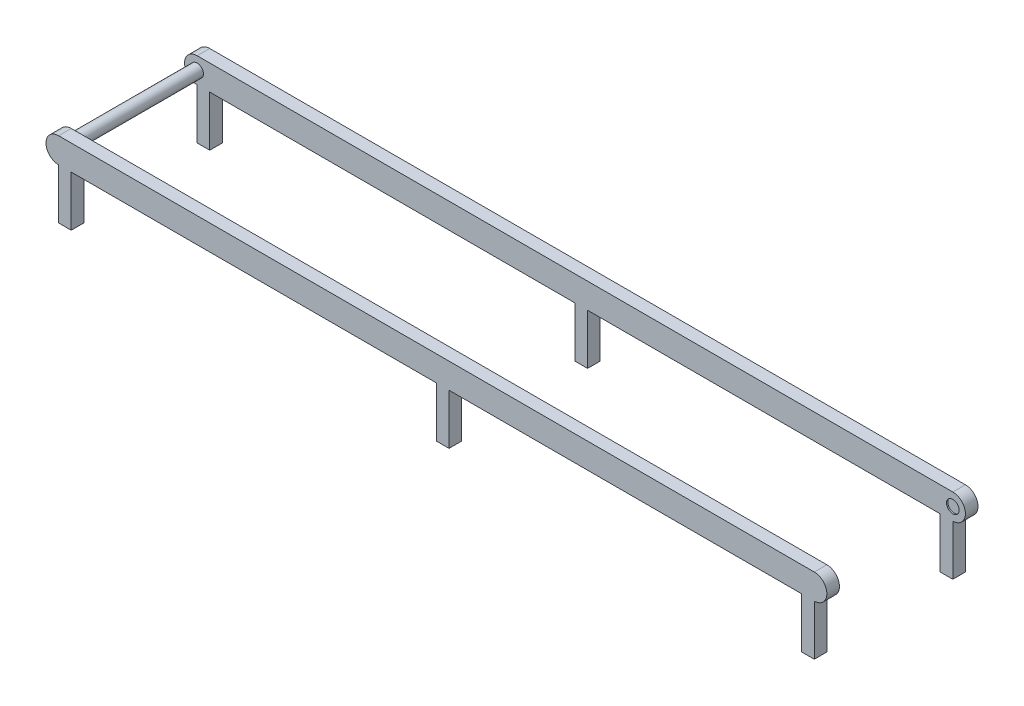
from build123d import *

# Parameters (mm, degrees)
SALIENTE_EXTRUIR1_DEPTH = 10
CROQUIS2_R              = 5
SALIENTE_EXTRUIR2_DEPTH = 100
CROQUIS5_R              = 5
CORTAR_EXTRUIR1_DEPTH   = 1
SALIENTE_EXTRUIR5_DEPTH = 10
CROQUIS7_W              = 10
CROQUIS7_H              = 10
SALIENTE_EXTRUIR6_DEPTH = 40


with BuildPart() as part:
    # Croquis1 → Saliente-Extruir1 (new body)
    with BuildSketch(Plane.XY):
        with BuildLine():
            Line((-300, 10), (300, 10))
            ThreePointArc((300, 10), (310, 0), (300, -10))
            Line((300, -10), (-300, -10))
            ThreePointArc((-300, -10), (-310, 0), (-300, 10))
        make_face()
    extrude(amount=SALIENTE_EXTRUIR1_DEPTH)

    # Croquis2 → Saliente-Extruir2 (add)
    with BuildSketch(Plane.XY.offset(10)):
        with Locations((-300, 0)):
            Circle(CROQUIS2_R)
    extrude(amount=SALIENTE_EXTRUIR2_DEPTH)

    # Croquis5 → Cortar-Extruir1 (cut)
    with BuildSketch(Plane.XY.offset(10)):
        with Locations((300, 0)):
            Circle(CROQUIS5_R)
    extrude(amount=-CORTAR_EXTRUIR1_DEPTH, mode=Mode.SUBTRACT)

    # Croquis6 → Saliente-Extruir5 (add)
    with BuildSketch(Plane.XY.offset(110)):
        with BuildLine():
            Line((-300, -10), (300, -10))
            ThreePointArc((300, -10), (310, 0), (300, 10))
            Line((300, 10), (-300, 10))
            ThreePointArc((-300, 10), (-310, 0), (-300, -10))
        make_face()
    extrude(amount=SALIENTE_EXTRUIR5_DEPTH)

    # Croquis7 → Saliente-Extruir6 (add)
    with BuildSketch(Plane.XZ.offset(10)):
        with Locations((-295, 5)):
            Rectangle(CROQUIS7_W, CROQUIS7_H)
        with Locations((295, 5)):
            Rectangle(CROQUIS7_W, CROQUIS7_H)
        with Locations((295, 115)):
            Rectangle(CROQUIS7_W, CROQUIS7_H)
        with Locations((-295, 115)):
            Rectangle(CROQUIS7_W, CROQUIS7_H)
        with Locations((5, 5)):
            Rectangle(CROQUIS7_W, CROQUIS7_H)
        with Locations((5, 115)):
            Rectangle(CROQUIS7_W, CROQUIS7_H)
    extrude(amount=SALIENTE_EXTRUIR6_DEPTH)


solid = part.part
